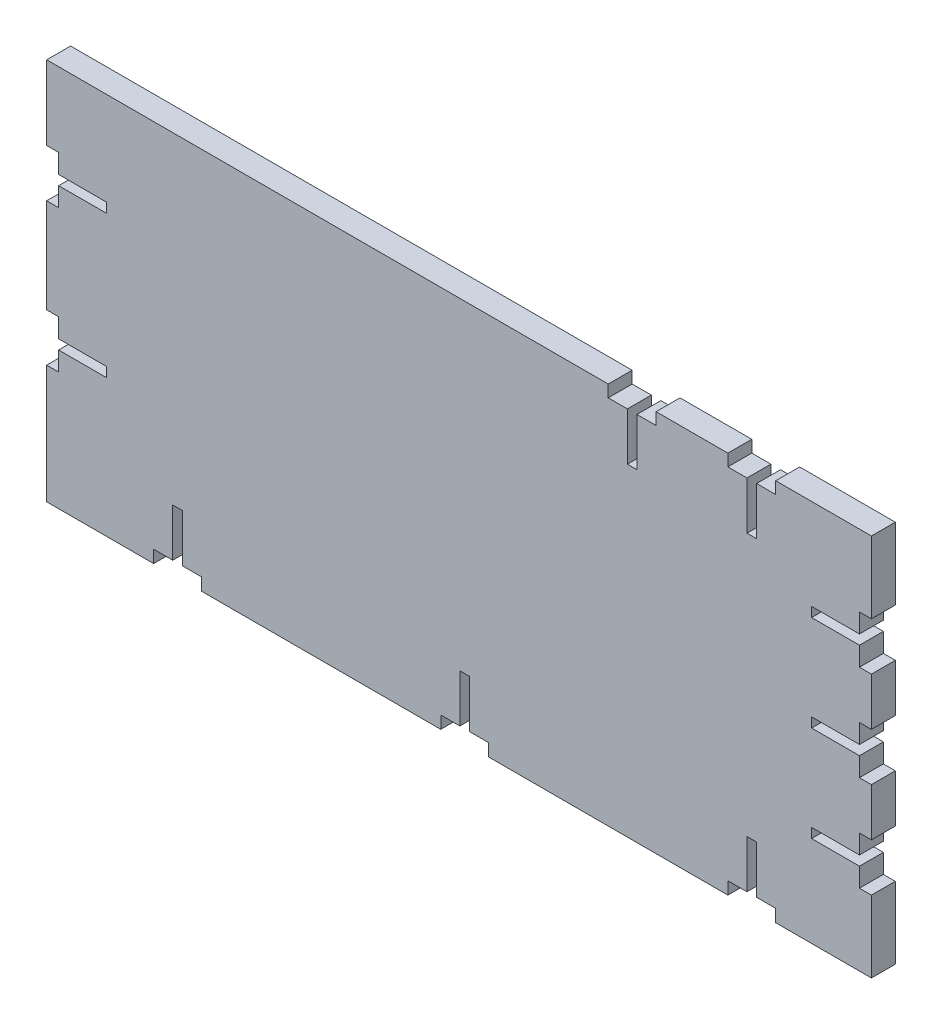
from build123d import *

# Parameters (mm, degrees)
BOSS_EXTRUDE1_DEPTH     = 6.35
CUT_EXTRUDE4_DEPTH      = 127
CUT_EXTRUDE4_DEPTH_BACK = 127
CUT_EXTRUDE5_DEPTH      = 127
CUT_EXTRUDE5_DEPTH_BACK = 127
CUT_EXTRUDE7_DEPTH      = 127
CUT_EXTRUDE7_DEPTH_BACK = 127
SKETCH5_W               = 229.808362084
SKETCH5_H               = 77.917038349


with BuildPart() as part:
    # Sketch1 → Boss-Extrude1 (new body)
    with BuildSketch(Plane.XY):
        Polygon((0, 0), (127, 0), (127, 101.6), (0, 101.6), (-70.692427737, 172.292427737), (-91.896861793, 151.087993682), (-91.896861793, 0), align=None)
    extrude(amount=BOSS_EXTRUDE1_DEPTH)

    # Sketch3 → Cut-Extrude4 (cut, two sides: drawn at the far end of the back side and taken through both)
    with BuildSketch(Plane(origin=(0, 0, 0), x_dir=(-1, 0, 0), z_dir=(0, 0, -1)).offset(-CUT_EXTRUDE4_DEPTH_BACK)):
        Polygon((68.447363707, 161.067107586), (63.957235647, 156.576979525), (66.202299677, 154.331915495), (70.692427737, 158.822043556), align=None)
        Polygon((-127, 31.75), (-127, 19.05), (-123.825, 19.05), (-123.825, 24.1173), (-111.125, 24.1173), (-111.125, 26.6827), (-123.825, 26.6827), (-123.825, 31.75), align=None)
        Polygon((-57.15, 101.6), (-69.85, 101.6), (-69.85, 98.425), (-64.77, 98.425), (-64.77, 85.725), (-62.23, 85.725), (-62.23, 98.425), (-57.15, 98.425), align=None)
        Polygon((-88.9, 101.6), (-101.6, 101.6), (-101.6, 98.425), (-96.5327, 98.425), (-96.5327, 85.725), (-93.9673, 85.725), (-93.9673, 98.425), (-88.9, 98.425), align=None)
        Polygon((-127, 82.55), (-127, 69.85), (-123.825, 69.85), (-123.825, 74.9173), (-111.125, 74.9173), (-111.125, 77.4827), (-123.825, 77.4827), (-123.825, 82.55), align=None)
        Polygon((-127, 57.15), (-127, 44.45), (-123.825, 44.45), (-123.825, 49.5173), (-111.125, 49.5173), (-111.125, 52.0827), (-123.825, 52.0827), (-123.825, 57.15), align=None)
        Polygon((88.721861793, 106.965995261), (91.896861793, 106.965995261), (91.896861793, 119.665995261), (88.721861793, 119.665995261), (88.721861793, 114.598695261), (76.021861793, 114.598695261), (76.021861793, 112.033295261), (88.721861793, 112.033295261), align=None)
        Polygon((88.721861793, 69.193996841), (91.896861793, 69.193996841), (91.896861793, 81.893996841), (88.721861793, 81.893996841), (88.721861793, 76.826696841), (76.021861793, 76.826696841), (76.021861793, 74.261296841), (88.721861793, 74.261296841), align=None)
        Polygon((88.721861793, 31.42199842), (91.896861793, 31.42199842), (91.896861793, 44.12199842), (88.721861793, 44.12199842), (88.721861793, 39.05469842), (76.021861793, 39.05469842), (76.021861793, 36.48929842), (88.721861793, 36.48929842), align=None)
        Polygon((50.8, 3.302), (50.8, 0), (63.5, 0), (63.5, 3.302), (58.4327, 3.302), (58.4327, 16.002), (55.8673, 16.002), (55.8673, 3.302), align=None)
        Polygon((-25.4, 3.302), (-25.4, 0), (-12.7, 0), (-12.7, 3.302), (-17.7673, 3.302), (-17.7673, 16.002), (-20.3327, 16.002), (-20.3327, 3.302), align=None)
        Polygon((-101.6, 3.302), (-101.6, 0), (-88.9, 0), (-88.9, 3.302), (-93.9673, 3.302), (-93.9673, 16.002), (-96.5327, 16.002), (-96.5327, 3.302), align=None)
    extrude(amount=CUT_EXTRUDE4_DEPTH + CUT_EXTRUDE4_DEPTH_BACK, mode=Mode.SUBTRACT)

    # Sketch4 → Cut-Extrude5 (cut, two sides: drawn at the far end of the back side and taken through both)
    with BuildSketch(Plane.XY.offset(-CUT_EXTRUDE5_DEPTH_BACK)):
        Polygon((-81.917747889, 147.596723404), (-79.672683858, 149.841787435), (-75.182555798, 145.351659374), (-77.427619828, 143.106595344), align=None)
    extrude(amount=CUT_EXTRUDE5_DEPTH + CUT_EXTRUDE5_DEPTH_BACK, mode=Mode.SUBTRACT)

    # Sketch5 → Cut-Extrude7 (cut, two sides: drawn at the far end of the back side and taken through both)
    with BuildSketch(Plane.XY.offset(-CUT_EXTRUDE7_DEPTH_BACK)):
        with Locations((12.095818958, 140.558519175)):
            Rectangle(SKETCH5_W, SKETCH5_H)
    extrude(amount=CUT_EXTRUDE7_DEPTH + CUT_EXTRUDE7_DEPTH_BACK, mode=Mode.SUBTRACT)


solid = part.part
